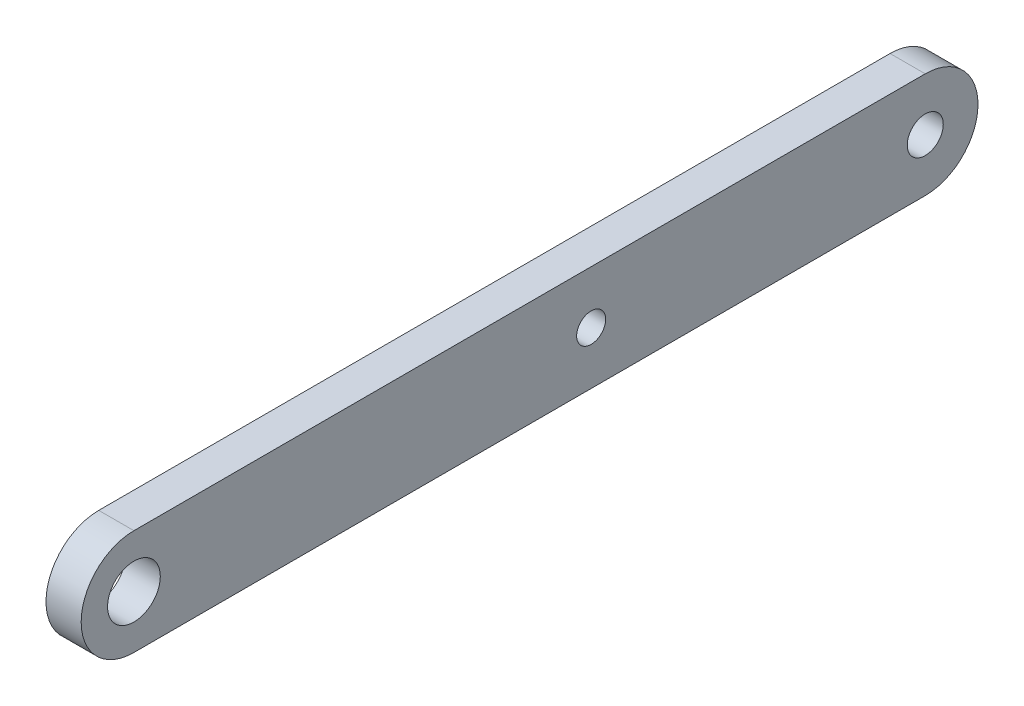
from build123d import *

# Parameters (mm, degrees)
SKETCH_1_R          = 3
SKETCH_1_R_2        = 2.05
EXTRUDE_1_DEPTH     = 4
SKETCH_2_R          = 1.65
CUT_EXTRUDE_1_DEPTH = 5


with BuildPart() as part:
    # 草图1 → 凸台-拉伸1 (new body)
    with BuildSketch(Plane(origin=(0, 0, 0), x_dir=(0, 0, -1), z_dir=(1, 0, 0))):
        with BuildLine():
            Line((0, 6), (90, 6))
            ThreePointArc((90, 6), (96, 0), (90, -6))
            Line((90, -6), (0, -6))
            ThreePointArc((0, -6), (-6, 0), (0, 6))
        make_face()
        Circle(SKETCH_1_R, mode=Mode.SUBTRACT)
        with Locations((90, 0)):
            Circle(SKETCH_1_R_2, mode=Mode.SUBTRACT)
    extrude(amount=EXTRUDE_1_DEPTH)

    # 草图2 → 切除-拉伸1 (cut, through all)
    with BuildSketch(Plane(origin=(4, 0, 0), x_dir=(0, 0, -1), z_dir=(1, 0, 0))):
        with Locations((52, 0)):
            Circle(SKETCH_2_R)
    extrude(amount=-CUT_EXTRUDE_1_DEPTH, mode=Mode.SUBTRACT)


solid = part.part
